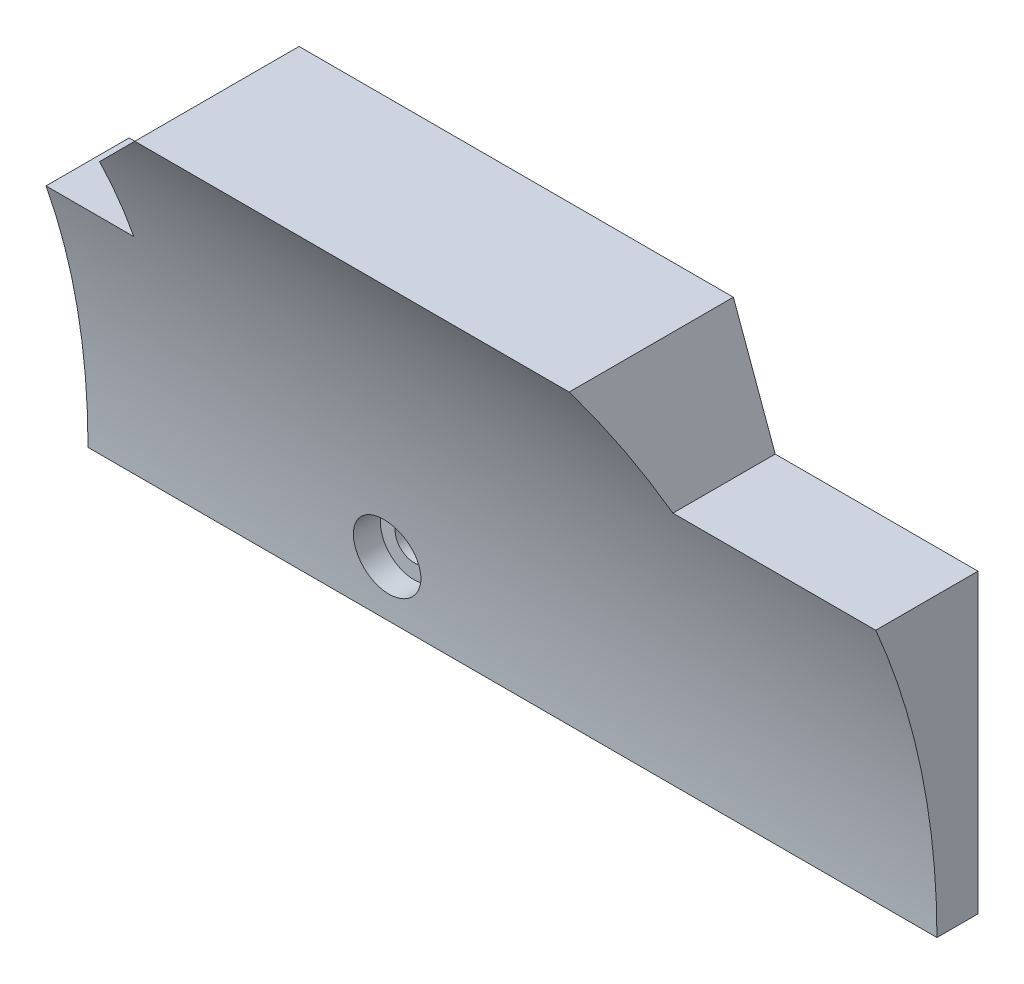
from build123d import *

# Parameters (mm, degrees)
AUFSATZ_LINEAR_AUSTRAGEN1_DEPTH = 10
SKIZZE2_R                       = 1.15
SCHNITT_LINEAR_AUSTRAGEN1_DEPTH = 11
SKIZZE3_R                       = 2.05
SCHNITT_LINEAR_AUSTRAGEN2_DEPTH = 2
SCHNITT_LINEAR_AUSTRAGEN3_DEPTH = 52.7
SCHNITT_LINEAR_START            = 1
SKIZZE5_R                       = 2.05
SCHNITT_LINEAR_AUSTRAGEN4_DEPTH = 10.0000001


with BuildPart() as part:
    # Skizze1 → Aufsatz-Linear austragen1 (new body)
    with BuildSketch(Plane.XY):
        Polygon((53.35, 39.925098055), (1.65, 39.925098055), (1.65, 46.925098055), (1.65, 55), (7, 55), (7, 60), (12, 65), (38.45220836, 65), (41, 58), (53.35, 58), (53.35, 46.925098055), align=None)
    extrude(amount=AUFSATZ_LINEAR_AUSTRAGEN1_DEPTH)

    # Skizze2 → Schnitt-Linear austragen1 (cut, through all)
    with BuildSketch(Plane.XY.offset(10)):
        with Locations((20, 43.425098055)):
            Circle(SKIZZE2_R)
    extrude(amount=-SCHNITT_LINEAR_AUSTRAGEN1_DEPTH, mode=Mode.SUBTRACT)

    # Skizze3 → Schnitt-Linear austragen2 (cut)
    with BuildSketch(Plane.XY.offset(10)):
        with Locations((20, 43.425098055)):
            Circle(SKIZZE3_R)
    extrude(amount=-SCHNITT_LINEAR_AUSTRAGEN2_DEPTH, mode=Mode.SUBTRACT)

    # Skizze4 → Schnitt-Linear austragen3 (cut, through all)
    with BuildSketch(Plane(origin=(53.35, 0, 0), x_dir=(0, 0, -1), z_dir=(1, 0, 0))):
        with BuildLine():
            Line((-10, 65), (-48.166713837, 39.925098055))
            Line((-48.166713837, 39.925098055), (-2.5, 39.925098055))
            ThreePointArc((-2.5, 39.925098055), (-4.415158713, 53.011357142), (-10, 65))
        make_face()
    extrude(amount=-SCHNITT_LINEAR_AUSTRAGEN3_DEPTH, mode=Mode.SUBTRACT)

    # Skizze5 → Schnitt-Linear austragen4 (cut, through all)
    with BuildSketch(Plane.XY.offset(SCHNITT_LINEAR_START)):
        with Locations((20, 43.425098055)):
            Circle(SKIZZE5_R)
    extrude(amount=SCHNITT_LINEAR_AUSTRAGEN4_DEPTH, mode=Mode.SUBTRACT)


solid = part.part
